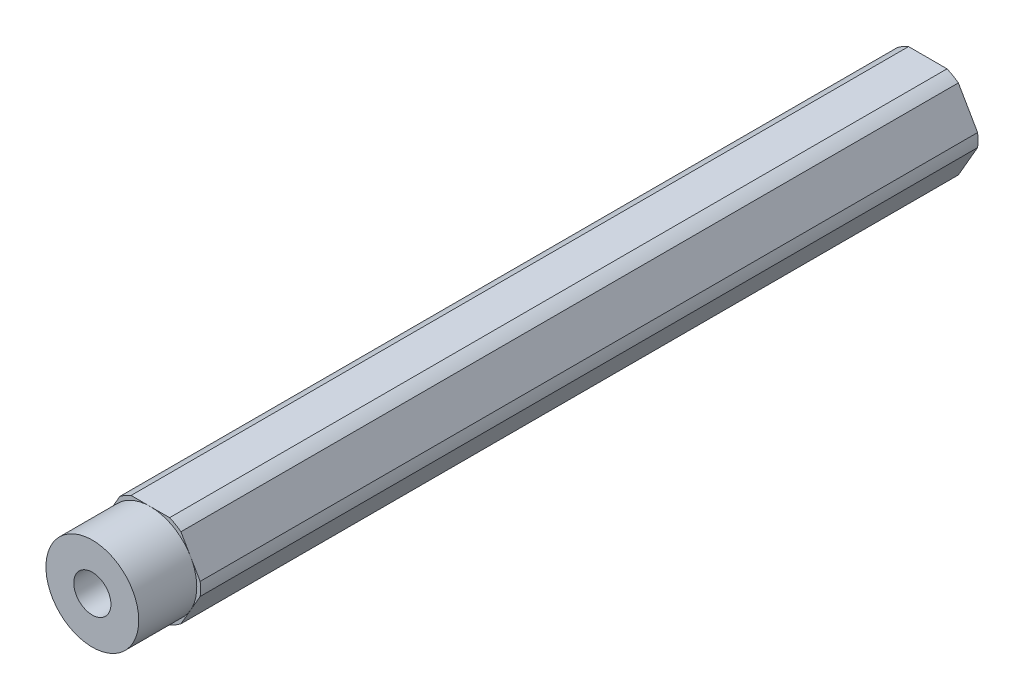
from build123d import *

# Parameters (mm, degrees)
SKETCH1_R           = 2.54
BOSS_EXTRUDE1_DEPTH = 114.3
SKETCH2_OUTSIDE_W   = 38.914
SKETCH2_OUTSIDE_H   = 37.864
SKETCH2_OUTSIDE_R   = 6.35
CUT_EXTRUDE1_DEPTH  = 7.9375


with BuildPart() as part:
    # Sketch1 → Boss-Extrude1 (new body)
    with BuildSketch(Plane.XY):
        with BuildLine():
            Line((4.181770802, -5.456960506), (6.816751826, -0.893039494))
            ThreePointArc((6.816751826, -0.893039494), (6.875, 0), (6.816751826, 0.893039494))
            Line((6.816751826, 0.893039494), (4.181770802, 5.456960506))
            ThreePointArc((4.181770802, 5.456960506), (3.4375, 5.953924651), (2.634981025, 6.35))
            Line((2.634981025, 6.35), (-2.634981025, 6.35))
            ThreePointArc((-2.634981025, 6.35), (-3.4375, 5.953924651), (-4.181770802, 5.456960506))
            Line((-4.181770802, 5.456960506), (-6.816751826, 0.893039494))
            ThreePointArc((-6.816751826, 0.893039494), (-6.875, 0), (-6.816751826, -0.893039494))
            Line((-6.816751826, -0.893039494), (-4.181770802, -5.456960506))
            ThreePointArc((-4.181770802, -5.456960506), (-3.4375, -5.953924651), (-2.634981025, -6.35))
            Line((-2.634981025, -6.35), (2.634981025, -6.35))
            ThreePointArc((2.634981025, -6.35), (3.4375, -5.953924651), (4.181770802, -5.456960506))
        make_face()
        Circle(SKETCH1_R, mode=Mode.SUBTRACT)
    extrude(amount=BOSS_EXTRUDE1_DEPTH)

    # Sketch2 outside → Cut-Extrude1 (cut)
    with BuildSketch(Plane.XY.offset(114.3)):
        Rectangle(SKETCH2_OUTSIDE_W, SKETCH2_OUTSIDE_H)
        Circle(SKETCH2_OUTSIDE_R, mode=Mode.SUBTRACT)
    extrude(amount=-CUT_EXTRUDE1_DEPTH, mode=Mode.SUBTRACT)


solid = part.part
